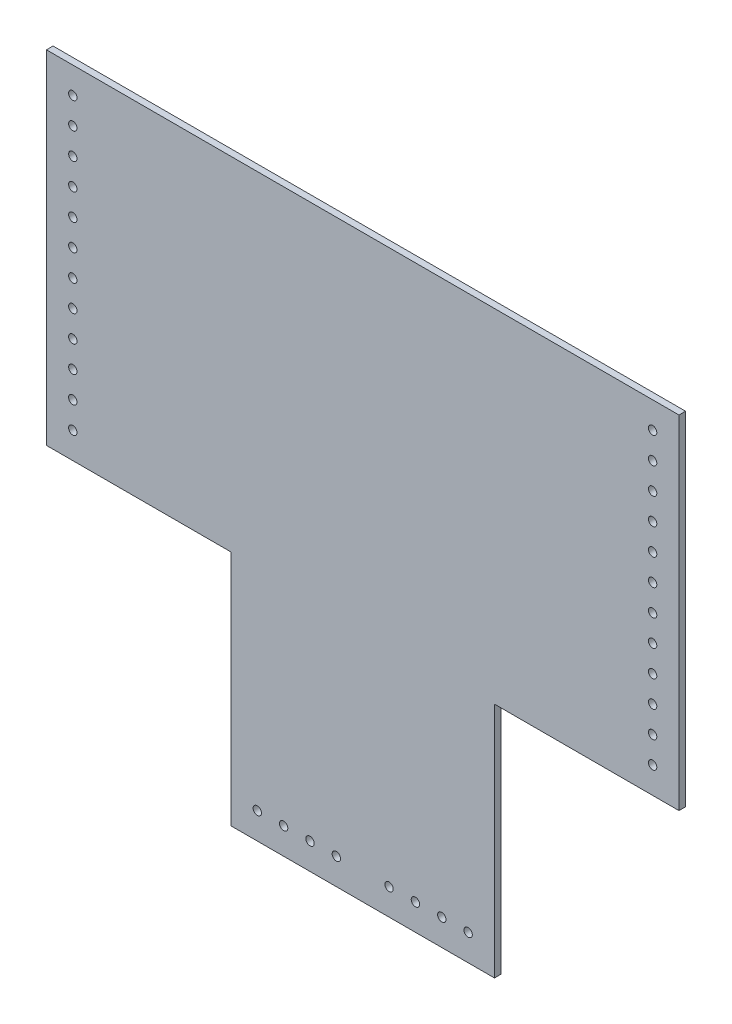
from build123d import *

# Parameters (mm, degrees)
SKETCH1_R           = 2.0193
BOSS_EXTRUDE1_DEPTH = 3.175


with BuildPart() as part:
    # Sketch1 → Boss-Extrude1 (new body)
    with BuildSketch(Plane.XY):
        Polygon((0, 114.3), (88.9, 114.3), (88.9, 0), (215.9, 0), (215.9, 114.3), (304.8, 114.3), (304.8, 279.4), (0, 279.4), align=None)
        with Locations((101.6, 12.7)):
            Circle(SKETCH1_R, mode=Mode.SUBTRACT)
        with Locations((114.3, 12.7)):
            Circle(SKETCH1_R, mode=Mode.SUBTRACT)
        with Locations((127, 12.7)):
            Circle(SKETCH1_R, mode=Mode.SUBTRACT)
        with Locations((139.7, 12.7)):
            Circle(SKETCH1_R, mode=Mode.SUBTRACT)
        with Locations((12.7, 127)):
            Circle(SKETCH1_R, mode=Mode.SUBTRACT)
        with Locations((12.7, 139.7)):
            Circle(SKETCH1_R, mode=Mode.SUBTRACT)
        with Locations((12.7, 152.4)):
            Circle(SKETCH1_R, mode=Mode.SUBTRACT)
        with Locations((12.7, 165.1)):
            Circle(SKETCH1_R, mode=Mode.SUBTRACT)
        with Locations((12.7, 177.8)):
            Circle(SKETCH1_R, mode=Mode.SUBTRACT)
        with Locations((12.7, 190.5)):
            Circle(SKETCH1_R, mode=Mode.SUBTRACT)
        with Locations((12.7, 203.2)):
            Circle(SKETCH1_R, mode=Mode.SUBTRACT)
        with Locations((12.7, 215.9)):
            Circle(SKETCH1_R, mode=Mode.SUBTRACT)
        with Locations((12.7, 228.6)):
            Circle(SKETCH1_R, mode=Mode.SUBTRACT)
        with Locations((12.7, 241.3)):
            Circle(SKETCH1_R, mode=Mode.SUBTRACT)
        with Locations((12.7, 254)):
            Circle(SKETCH1_R, mode=Mode.SUBTRACT)
        with Locations((12.7, 266.7)):
            Circle(SKETCH1_R, mode=Mode.SUBTRACT)
        with Locations((292.1, 266.7)):
            Circle(SKETCH1_R, mode=Mode.SUBTRACT)
        with Locations((292.1, 254)):
            Circle(SKETCH1_R, mode=Mode.SUBTRACT)
        with Locations((292.1, 241.3)):
            Circle(SKETCH1_R, mode=Mode.SUBTRACT)
        with Locations((292.1, 228.6)):
            Circle(SKETCH1_R, mode=Mode.SUBTRACT)
        with Locations((292.1, 215.9)):
            Circle(SKETCH1_R, mode=Mode.SUBTRACT)
        with Locations((292.1, 203.2)):
            Circle(SKETCH1_R, mode=Mode.SUBTRACT)
        with Locations((292.1, 190.5)):
            Circle(SKETCH1_R, mode=Mode.SUBTRACT)
        with Locations((292.1, 177.8)):
            Circle(SKETCH1_R, mode=Mode.SUBTRACT)
        with Locations((292.1, 165.1)):
            Circle(SKETCH1_R, mode=Mode.SUBTRACT)
        with Locations((292.1, 152.4)):
            Circle(SKETCH1_R, mode=Mode.SUBTRACT)
        with Locations((292.1, 139.7)):
            Circle(SKETCH1_R, mode=Mode.SUBTRACT)
        with Locations((292.1, 127)):
            Circle(SKETCH1_R, mode=Mode.SUBTRACT)
        with Locations((165.1, 12.7)):
            Circle(SKETCH1_R, mode=Mode.SUBTRACT)
        with Locations((177.8, 12.7)):
            Circle(SKETCH1_R, mode=Mode.SUBTRACT)
        with Locations((190.5, 12.7)):
            Circle(SKETCH1_R, mode=Mode.SUBTRACT)
        with Locations((203.2, 12.7)):
            Circle(SKETCH1_R, mode=Mode.SUBTRACT)
    extrude(amount=BOSS_EXTRUDE1_DEPTH)


solid = part.part
